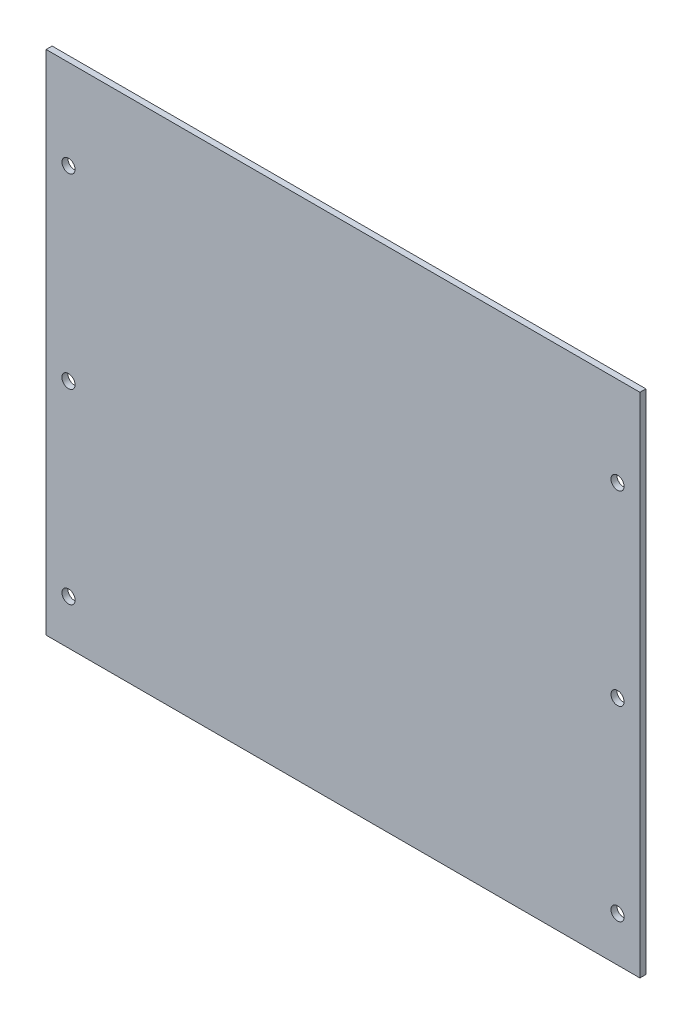
from build123d import *

# Parameters (mm, degrees)
SKETCH_1_W          = 199
SKETCH_1_H          = 170
EXTRUDE_1_DEPTH     = 2
SKETCH_2_R          = 2.2
CUT_EXTRUDE_1_DEPTH = 2


with BuildPart() as part:
    # ｽｹｯﾁ1 → ﾎﾞｽ - 押し出し1 (new body)
    with BuildSketch(Plane.XY):
        Rectangle(SKETCH_1_W, SKETCH_1_H)
    extrude(amount=EXTRUDE_1_DEPTH)

    # ｽｹｯﾁ2 → ｶｯﾄ - 押し出し1 (cut)
    with BuildSketch(Plane.XY.offset(2)):
        with Locations((-92, -70)):
            Circle(SKETCH_2_R)
        with Locations((-92, -7.5)):
            Circle(SKETCH_2_R)
        with Locations((-92, 55)):
            Circle(SKETCH_2_R)
        with Locations((92, -70)):
            Circle(SKETCH_2_R)
        with Locations((92, -7.5)):
            Circle(SKETCH_2_R)
        with Locations((92, 55)):
            Circle(SKETCH_2_R)
    extrude(amount=-CUT_EXTRUDE_1_DEPTH, mode=Mode.SUBTRACT)


solid = part.part
